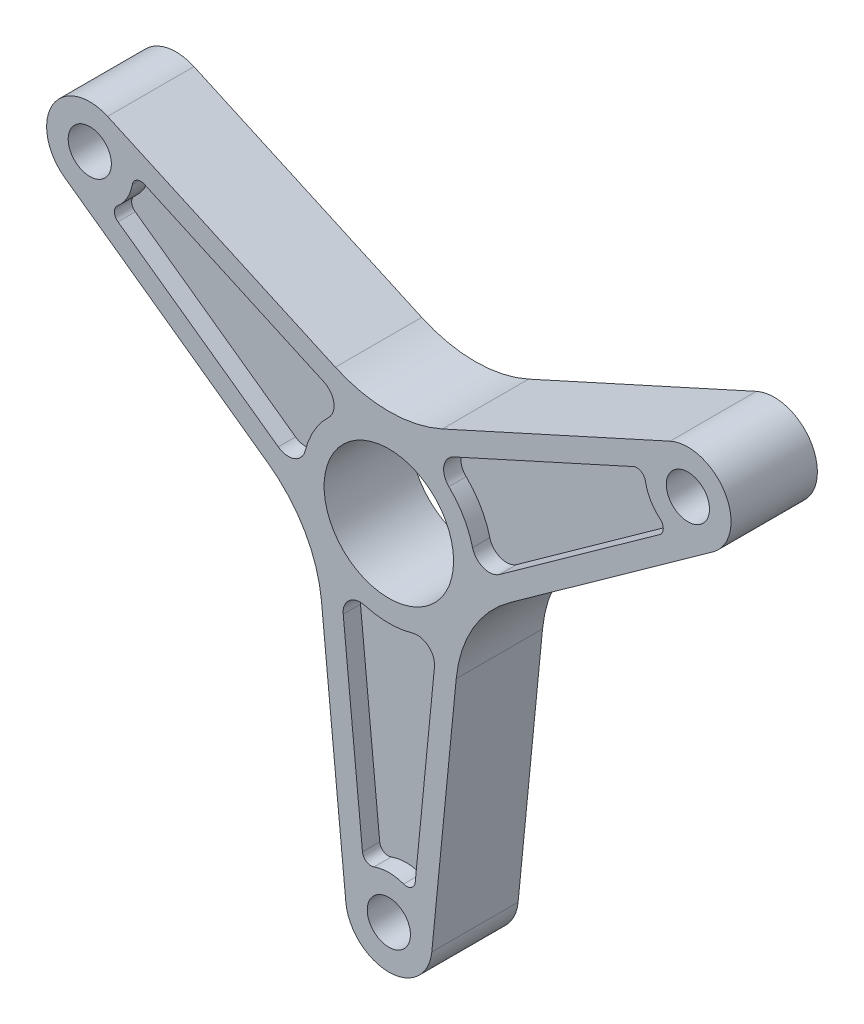
from build123d import *

# Parameters (mm, degrees)
SKETCH1_R           = 15
SKETCH1_R_2         = 5
BOSS_EXTRUDE2_DEPTH = 20
SKETCH7_OUTSIDE_W   = 203.058
SKETCH7_OUTSIDE_H   = 184.494
CUT_EXTRUDE4_DEPTH  = 4
CUT_EXTRUDE5_DEPTH  = 4


with BuildPart() as part:
    # Sketch1 → Boss-Extrude2 (new body)
    with BuildSketch(Plane.XY):
        with BuildLine():
            Line((-9.952202212, -80.976560871), (-15.609727063, -23.320317388))
            ThreePointArc((-15.609727063, -23.320317388), (-19.485571585, -11.25), (-28.000850814, -1.858261489))
            Line((-28.000850814, -1.858261489), (-75.103859931, 31.869420496))
            ThreePointArc((-75.103859931, 31.869420496), (-77.942286341, 45), (-65.151657719, 49.107140374))
            Line((-65.151657719, 49.107140374), (-12.391123751, 25.178578877))
            ThreePointArc((-12.391123751, 25.178578877), (0, 22.5), (12.391123751, 25.178578877))
            Line((12.391123751, 25.178578877), (65.151657719, 49.107140374))
            ThreePointArc((65.151657719, 49.107140374), (77.942286341, 45), (75.103859931, 31.869420496))
            Line((75.103859931, 31.869420496), (28.000850814, -1.858261489))
            ThreePointArc((28.000850814, -1.858261489), (19.485571585, -11.25), (15.609727063, -23.320317388))
            Line((15.609727063, -23.320317388), (9.952202212, -80.976560871))
            ThreePointArc((9.952202212, -80.976560871), (0, -90), (-9.952202212, -80.976560871))
        make_face()
        Circle(SKETCH1_R, mode=Mode.SUBTRACT)
        with Locations((0, -80)):
            Circle(SKETCH1_R_2, mode=Mode.SUBTRACT)
        with Locations((-69.282032303, 40)):
            Circle(SKETCH1_R_2, mode=Mode.SUBTRACT)
        with Locations((69.282032303, 40)):
            Circle(SKETCH1_R_2, mode=Mode.SUBTRACT)
    extrude(amount=BOSS_EXTRUDE2_DEPTH)

    # Sketch7 outside → Cut-Extrude4 (cut)
    with BuildSketch(Plane.XY.offset(20)):
        with Locations((0, -20)):
            Rectangle(SKETCH7_OUTSIDE_W, SKETCH7_OUTSIDE_H)
        with BuildLine():
            Line((-15.609727063, -23.320317388), (-9.952202212, -80.976560871))
            ThreePointArc((-9.952202212, -80.976560871), (0, -90), (9.952202212, -80.976560871))
            Line((9.952202212, -80.976560871), (15.609727063, -23.320317388))
            ThreePointArc((15.609727063, -23.320317388), (19.485571585, -11.25), (28.000850814, -1.858261489))
            Line((28.000850814, -1.858261489), (75.103859931, 31.869420496))
            ThreePointArc((75.103859931, 31.869420496), (77.942286341, 45), (65.151657719, 49.107140374))
            Line((65.151657719, 49.107140374), (12.391123751, 25.178578877))
            ThreePointArc((12.391123751, 25.178578877), (0, 22.5), (-12.391123751, 25.178578877))
            Line((-12.391123751, 25.178578877), (-65.151657719, 49.107140374))
            ThreePointArc((-65.151657719, 49.107140374), (-77.942286341, 45), (-75.103859931, 31.869420496))
            Line((-75.103859931, 31.869420496), (-28.000850814, -1.858261489))
            ThreePointArc((-28.000850814, -1.858261489), (-19.485571585, -11.25), (-15.609727063, -23.320317388))
        make_face(mode=Mode.SUBTRACT)
        with BuildLine():
            Line((-25.609534097, 2.579081047), (-62.746066413, 29.170357813))
            ThreePointArc((-62.746066413, 29.170357813), (-63.580283737, 30.721196932), (-62.865089457, 32.330394762))
            ThreePointArc((-62.865089457, 32.330394762), (-60.621778265, 35), (-59.431487906, 38.2775671))
            ThreePointArc((-59.431487906, 38.2775671), (-58.395478846, 39.70154243), (-56.63530411, 39.754508595))
            Line((-56.63530411, 39.754508595), (-15.038316754, 20.888966584))
            ThreePointArc((-15.038316754, 20.888966584), (-12.749228932, 17.929225173), (-13.908722156, 14.371758695))
            ThreePointArc((-13.908722156, 14.371758695), (-17.320508076, 10), (-19.400669205, 4.859427374))
            ThreePointArc((-19.400669205, 4.859427374), (-21.901778936, 2.076543547), (-25.609534097, 2.579081047))
        make_face()
        with BuildLine():
            Line((25.609534097, 2.579081047), (62.746066413, 29.170357813))
            ThreePointArc((62.746066413, 29.170357813), (63.580283737, 30.721196932), (62.865089457, 32.330394762))
            ThreePointArc((62.865089457, 32.330394762), (60.621778265, 35), (59.431487906, 38.2775671))
            ThreePointArc((59.431487906, 38.2775671), (58.395478846, 39.70154243), (56.63530411, 39.754508595))
            Line((56.63530411, 39.754508595), (15.038316754, 20.888966584))
            ThreePointArc((15.038316754, 20.888966584), (12.749228932, 17.929225173), (13.908722156, 14.371758695))
            ThreePointArc((13.908722156, 14.371758695), (17.320508076, 10), (19.400669205, 4.859427374))
            ThreePointArc((19.400669205, 4.859427374), (21.901778936, 2.076543547), (25.609534097, 2.579081047))
        make_face()
        with BuildLine():
            Line((-10.571217344, -23.468047631), (-6.110762303, -68.924866408))
            ThreePointArc((-6.110762303, -68.924866408), (-5.184804891, -70.422739362), (-3.43360155, -70.607961862))
            ThreePointArc((-3.43360155, -70.607961862), (0, -70), (3.43360155, -70.607961862))
            ThreePointArc((3.43360155, -70.607961862), (5.184804891, -70.422739362), (6.110762303, -68.924866408))
            Line((6.110762303, -68.924866408), (10.571217344, -23.468047631))
            ThreePointArc((10.571217344, -23.468047631), (9.152550004, -20.00576872), (5.491947049, -19.231186069))
            ThreePointArc((5.491947049, -19.231186069), (0, -20), (-5.491947049, -19.231186069))
            ThreePointArc((-5.491947049, -19.231186069), (-9.152550004, -20.00576872), (-10.571217344, -23.468047631))
        make_face()
    extrude(amount=-CUT_EXTRUDE4_DEPTH, mode=Mode.SUBTRACT)

    # Sketch3 → Cut-Extrude5 (cut)
    with BuildSketch(Plane(origin=(0, 0, 0), x_dir=(-1, 0, 0), z_dir=(0, 0, -1))):
        with BuildLine():
            Line((10.571217344, -23.468047631), (6.110762303, -68.924866408))
            ThreePointArc((6.110762303, -68.924866408), (5.184804891, -70.422739362), (3.43360155, -70.607961862))
            ThreePointArc((3.43360155, -70.607961862), (0, -70), (-3.43360155, -70.607961862))
            ThreePointArc((-3.43360155, -70.607961862), (-5.184804891, -70.422739362), (-6.110762303, -68.924866408))
            Line((-6.110762303, -68.924866408), (-10.571217344, -23.468047631))
            ThreePointArc((-10.571217344, -23.468047631), (-9.152550004, -20.00576872), (-5.491947049, -19.231186069))
            ThreePointArc((-5.491947049, -19.231186069), (0, -20), (5.491947049, -19.231186069))
            ThreePointArc((5.491947049, -19.231186069), (9.152550004, -20.00576872), (10.571217344, -23.468047631))
        make_face()
        with BuildLine():
            Line((-25.609534097, 2.579081047), (-62.746066413, 29.170357813))
            ThreePointArc((-62.746066413, 29.170357813), (-63.580283737, 30.721196932), (-62.865089457, 32.330394762))
            ThreePointArc((-62.865089457, 32.330394762), (-60.621778265, 35), (-59.431487906, 38.2775671))
            ThreePointArc((-59.431487906, 38.2775671), (-58.395478846, 39.70154243), (-56.63530411, 39.754508595))
            Line((-56.63530411, 39.754508595), (-15.038316754, 20.888966584))
            ThreePointArc((-15.038316754, 20.888966584), (-12.749228932, 17.929225173), (-13.908722156, 14.371758695))
            ThreePointArc((-13.908722156, 14.371758695), (-17.320508076, 10), (-19.400669205, 4.859427374))
            ThreePointArc((-19.400669205, 4.859427374), (-21.901778936, 2.076543547), (-25.609534097, 2.579081047))
        make_face()
        with BuildLine():
            Line((15.038316754, 20.888966584), (56.63530411, 39.754508595))
            ThreePointArc((56.63530411, 39.754508595), (58.395478846, 39.70154243), (59.431487906, 38.2775671))
            ThreePointArc((59.431487906, 38.2775671), (60.621778265, 35), (62.865089457, 32.330394762))
            ThreePointArc((62.865089457, 32.330394762), (63.580283737, 30.721196932), (62.746066413, 29.170357813))
            Line((62.746066413, 29.170357813), (25.609534097, 2.579081047))
            ThreePointArc((25.609534097, 2.579081047), (21.901778936, 2.076543547), (19.400669205, 4.859427374))
            ThreePointArc((19.400669205, 4.859427374), (17.320508076, 10), (13.908722156, 14.371758695))
            ThreePointArc((13.908722156, 14.371758695), (12.749228932, 17.929225173), (15.038316754, 20.888966584))
        make_face()
    extrude(amount=-CUT_EXTRUDE5_DEPTH, mode=Mode.SUBTRACT)


solid = part.part
